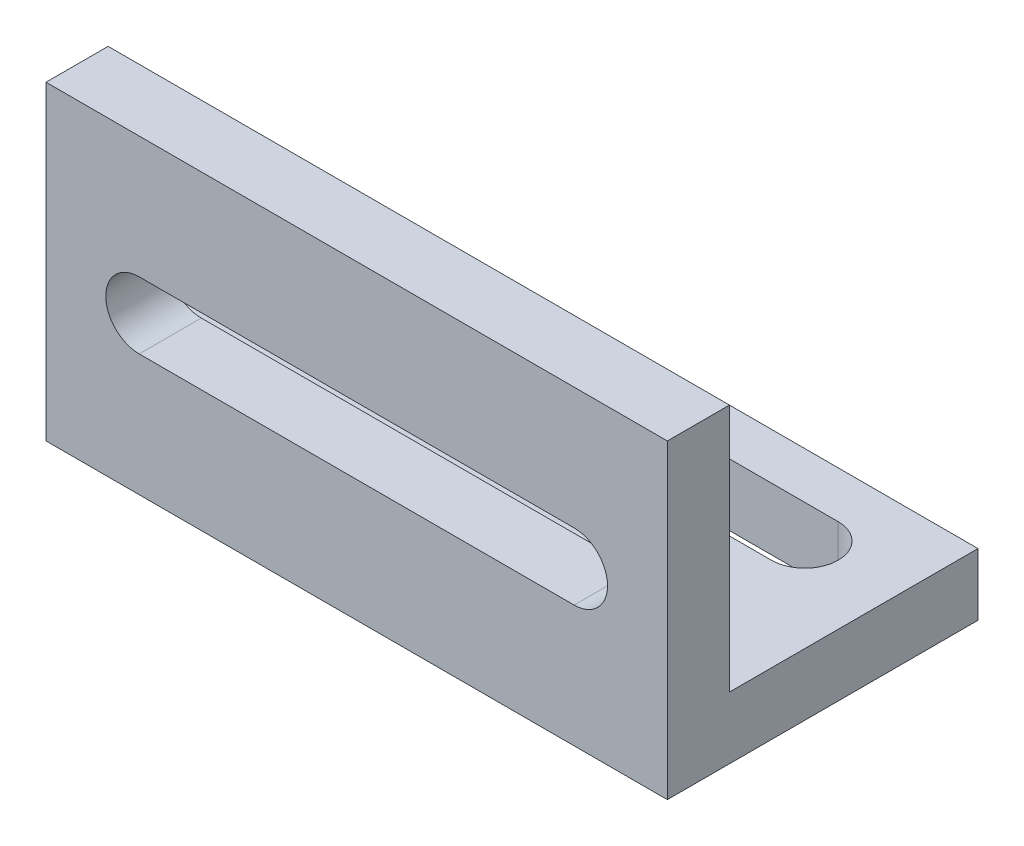
from build123d import *

# Parameters (mm, degrees)
SKETCH1_W           = 40
SKETCH1_H           = 20
BOSS_EXTRUDE1_DEPTH = 4
SKETCH5_W           = 40
SKETCH5_H           = 4
BOSS_EXTRUDE2_DEPTH = 16
CUT_EXTRUDE3_DEPTH  = 10
CUT_EXTRUDE5_DEPTH  = 10


with BuildPart() as part:
    # Sketch1 → Boss-Extrude1 (new body)
    with BuildSketch(Plane(origin=(0, 0, 0), x_dir=(1, 0, 0), z_dir=(0, 1, 0))):
        with Locations((-29.259259259, 2.888888889)):
            Rectangle(SKETCH1_W, SKETCH1_H)
    extrude(amount=BOSS_EXTRUDE1_DEPTH)

    # Sketch5 → Boss-Extrude2 (add)
    with BuildSketch(Plane(origin=(0, 4, 0), x_dir=(1, 0, 0), z_dir=(0, 1, 0))):
        with Locations((-29.259259259, -5.111111111)):
            Rectangle(SKETCH5_W, SKETCH5_H)
    extrude(amount=BOSS_EXTRUDE2_DEPTH)

    # Sketch7 → Cut-Extrude3 (cut)
    with BuildSketch(Plane(origin=(0, 4, 0), x_dir=(1, 0, 0), z_dir=(0, 1, 0))):
        with BuildLine():
            Line((-15.259259259, 5.588888889), (-43.259259259, 5.588888889))
            ThreePointArc((-43.259259259, 5.588888889), (-45.409259259, 7.738888889), (-43.259259259, 9.888888889))
            Line((-43.259259259, 9.888888889), (-15.259259259, 9.888888889))
            ThreePointArc((-15.259259259, 9.888888889), (-13.109259259, 7.738888889), (-15.259259259, 5.588888889))
        make_face()
    extrude(amount=-CUT_EXTRUDE3_DEPTH, mode=Mode.SUBTRACT)

    # Sketch8 → Cut-Extrude5 (cut)
    with BuildSketch(Plane(origin=(0, 0, 3.111111111), x_dir=(-1, 0, 0), z_dir=(0, 0, -1))):
        with BuildLine():
            Line((15.259259259, 12.15), (43.259259259, 12.15))
            ThreePointArc((43.259259259, 12.15), (45.409259259, 10), (43.259259259, 7.85))
            Line((43.259259259, 7.85), (15.259259259, 7.85))
            ThreePointArc((15.259259259, 7.85), (13.109259259, 10), (15.259259259, 12.15))
        make_face()
    extrude(amount=-CUT_EXTRUDE5_DEPTH, mode=Mode.SUBTRACT)


solid = part.part
